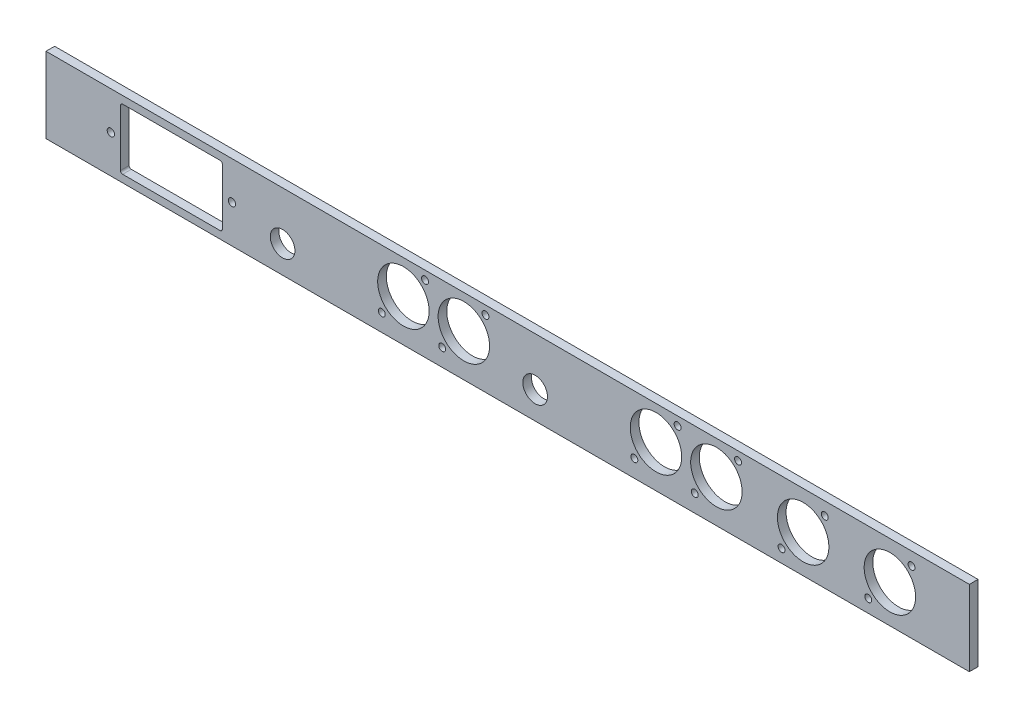
from build123d import *

# Parameters (mm, degrees)
SKETCH1_W           = 427
SKETCH1_H           = 35
BOSS_EXTRUDE1_DEPTH = 4
SKETCH2_R           = 11.9
SKETCH2_R_2         = 1.6
SKETCH2_R_3         = 5.7
SKETCH2_R_4         = 1.7
CUT_EXTRUDE1_DEPTH  = 4


with BuildPart() as part:
    # Sketch1 → Boss-Extrude1 (new body)
    with BuildSketch(Plane.XY):
        Rectangle(SKETCH1_W, SKETCH1_H)
    extrude(amount=BOSS_EXTRUDE1_DEPTH)

    # Sketch2 → Cut-Extrude1 (cut)
    with BuildSketch(Plane.XY.offset(4)):
        with Locations((-20.271803936, 2)):
            Circle(SKETCH2_R)
        with Locations((-30.271803936, -9.5)):
            Circle(SKETCH2_R_2)
        with Locations((-10.271803936, 13.5)):
            Circle(SKETCH2_R_2)
        with Locations((-58.211803936, -9.5)):
            Circle(SKETCH2_R_2)
        with Locations((-48.211803936, 2)):
            Circle(SKETCH2_R)
        with Locations((-38.211803936, 13.5)):
            Circle(SKETCH2_R_2)
        with Locations((126.64, -11.5)):
            Circle(SKETCH2_R_2)
        with Locations((146.64, 11.5)):
            Circle(SKETCH2_R_2)
        with Locations((136.64, 0)):
            Circle(SKETCH2_R)
        with Locations((166.76, -11.5)):
            Circle(SKETCH2_R_2)
        with Locations((186.76, 11.5)):
            Circle(SKETCH2_R_2)
        with Locations((176.76, 0)):
            Circle(SKETCH2_R)
        with Locations((-104.091803936, -4.865)):
            Circle(SKETCH2_R_3)
        with Locations((86.52, -9.5)):
            Circle(SKETCH2_R_2)
        with Locations((106.52, 13.5)):
            Circle(SKETCH2_R_2)
        with Locations((68.58, 2)):
            Circle(SKETCH2_R)
        with Locations((96.52, 2)):
            Circle(SKETCH2_R)
        with Locations((12.7, -4.865)):
            Circle(SKETCH2_R_3)
        with Locations((78.58, 13.5)):
            Circle(SKETCH2_R_2)
        with Locations((58.58, -9.5)):
            Circle(SKETCH2_R_2)
        with Locations((-127.5, 0)):
            Circle(SKETCH2_R_4)
        with Locations((-183.5, 0)):
            Circle(SKETCH2_R_4)
        with BuildLine():
            Line((-178.05, -14.05), (-132.95, -14.05))
            ThreePointArc((-132.95, -14.05), (-132.242893219, -13.757106781), (-131.95, -13.05))
            Line((-131.95, -13.05), (-131.95, 13.05))
            ThreePointArc((-131.95, 13.05), (-132.242893219, 13.757106781), (-132.95, 14.05))
            Line((-132.95, 14.05), (-178.05, 14.05))
            ThreePointArc((-178.05, 14.05), (-178.757106781, 13.757106781), (-179.05, 13.05))
            Line((-179.05, 13.05), (-179.05, -13.05))
            ThreePointArc((-179.05, -13.05), (-178.757106781, -13.757106781), (-178.05, -14.05))
        make_face()
    extrude(amount=-CUT_EXTRUDE1_DEPTH, mode=Mode.SUBTRACT)


solid = part.part
